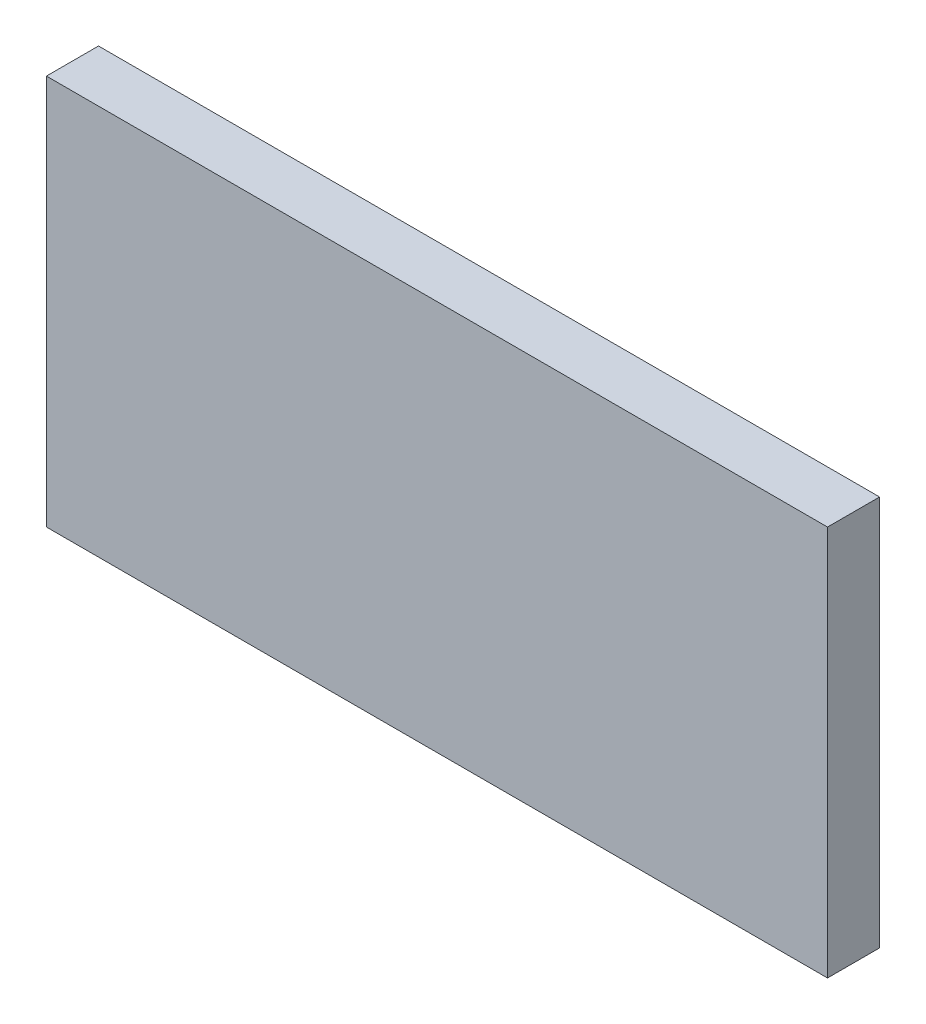
from build123d import *

# Parameters (mm, degrees)
SKETCH1_W           = 300
SKETCH1_H           = 150
BOSS_EXTRUDE1_DEPTH = 20
SKETCH2_W           = 80.25
SKETCH2_H           = 30
CUT_EXTRUDE1_DEPTH  = 15
SKETCH3_R           = 10
BOSS_EXTRUDE2_DEPTH = 20


with BuildPart() as part:
    # Sketch1 → Boss-Extrude1 (new body)
    with BuildSketch(Plane.XY):
        Rectangle(SKETCH1_W, SKETCH1_H)
    extrude(amount=BOSS_EXTRUDE1_DEPTH)

    # Sketch2 → Cut-Extrude1 (cut)
    with BuildSketch(Plane(origin=(0, 0, 0), x_dir=(-1, 0, 0), z_dir=(0, 0, -1))):
        with Locations((50.125, 0)):
            Rectangle(SKETCH2_W, SKETCH2_H)
    extrude(amount=-CUT_EXTRUDE1_DEPTH, mode=Mode.SUBTRACT)

    # Sketch3 → Boss-Extrude2 (add)
    with BuildSketch(Plane(origin=(0, 30, 0), x_dir=(1, 0, 0), z_dir=(0, 1, 0))):
        with BuildLine():
            Line((56.38, 0), (56.38, 12.86))
            ThreePointArc((56.38, 12.86), (76.38, 32.86), (96.38, 12.86))
            Line((96.38, 12.86), (96.38, 0))
            Line((96.38, 0), (56.38, 0))
        make_face()
        with Locations((76.38, 12.86)):
            Circle(SKETCH3_R, mode=Mode.SUBTRACT)
    extrude(amount=-BOSS_EXTRUDE2_DEPTH)


solid = part.part
